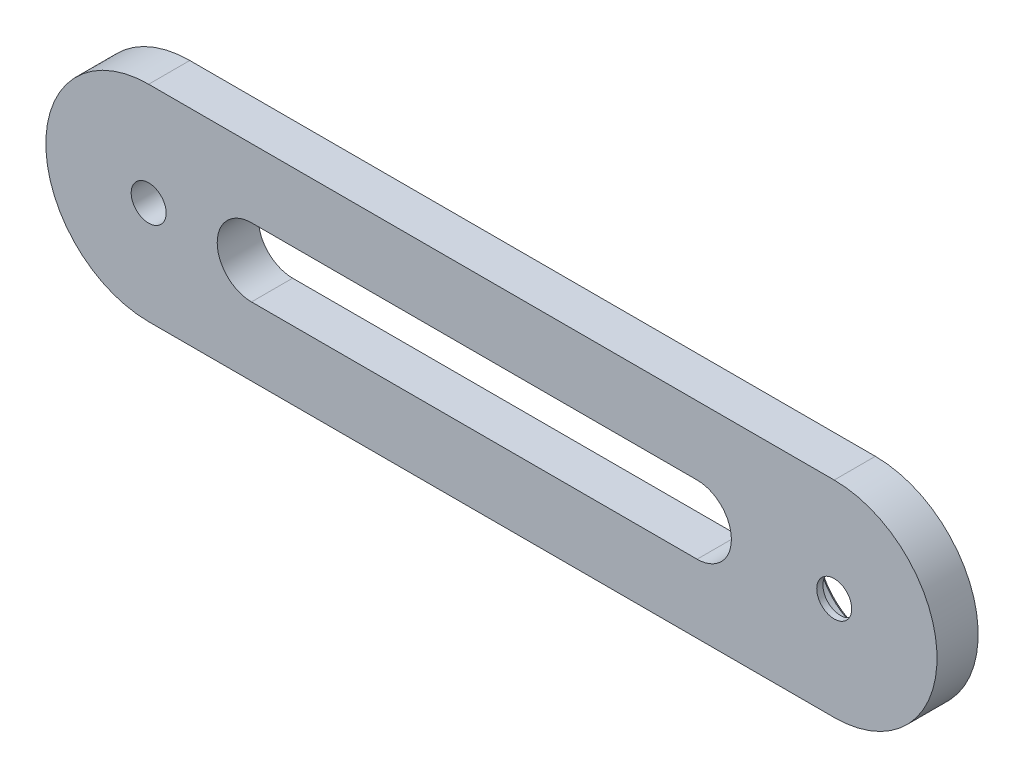
from build123d import *

# Parameters (mm, degrees)
BOSS_EXTRUDE1_DEPTH = 6
SKETCH9_R           = 7.975
CUT_EXTRUDE5_DEPTH  = 5.1
SKETCH10_R          = 2.55
CUT_EXTRUDE6_DEPTH  = 1.9
SKETCH11_R          = 2.55
CUT_EXTRUDE7_DEPTH  = 7
CHAMFER1_SIZE       = 0.5
CUT_EXTRUDE8_DEPTH  = 7


with BuildPart() as part:
    # Sketch4 → Boss-Extrude1 (new body)
    with BuildSketch(Plane.XY):
        with BuildLine():
            Line((-50, 15), (50, 15))
            ThreePointArc((50, 15), (65, 0), (50, -15))
            Line((50, -15), (-50, -15))
            ThreePointArc((-50, -15), (-65, 0), (-50, 15))
        make_face()
    extrude(amount=BOSS_EXTRUDE1_DEPTH)

    # Sketch9 → Cut-Extrude5 (cut)
    with BuildSketch(Plane(origin=(0, 0, 0), x_dir=(-1, 0, 0), z_dir=(0, 0, -1))):
        with Locations((-50, 0)):
            Circle(SKETCH9_R)
    extrude(amount=-CUT_EXTRUDE5_DEPTH, mode=Mode.SUBTRACT)

    # Sketch10 → Cut-Extrude6 (cut, through all)
    with BuildSketch(Plane(origin=(0, 0, 5.1), x_dir=(-1, 0, 0), z_dir=(0, 0, -1))):
        with Locations((-50, 0)):
            Circle(SKETCH10_R)
    extrude(amount=-CUT_EXTRUDE6_DEPTH, mode=Mode.SUBTRACT)

    # Sketch11 → Cut-Extrude7 (cut, through all)
    with BuildSketch(Plane(origin=(0, 0, 0), x_dir=(-1, 0, 0), z_dir=(0, 0, -1))):
        with Locations((50, 0)):
            Circle(SKETCH11_R)
    extrude(amount=-CUT_EXTRUDE7_DEPTH, mode=Mode.SUBTRACT)

    # Chamfer1
    chamfer1_edges = [part.edges().sort_by_distance(p)[0] for p in [
        (57.975, 0, 0),
    ]]
    chamfer(chamfer1_edges, length=CHAMFER1_SIZE)

    # Sketch12 → Cut-Extrude8 (cut, through all)
    with BuildSketch(Plane(origin=(0, 0, 0), x_dir=(-1, 0, 0), z_dir=(0, 0, -1))):
        with BuildLine():
            Line((-30, 5), (35, 5))
            ThreePointArc((35, 5), (40, 0), (35, -5))
            Line((35, -5), (-30, -5))
            ThreePointArc((-30, -5), (-35, 0), (-30, 5))
        make_face()
    extrude(amount=-CUT_EXTRUDE8_DEPTH, mode=Mode.SUBTRACT)


solid = part.part
